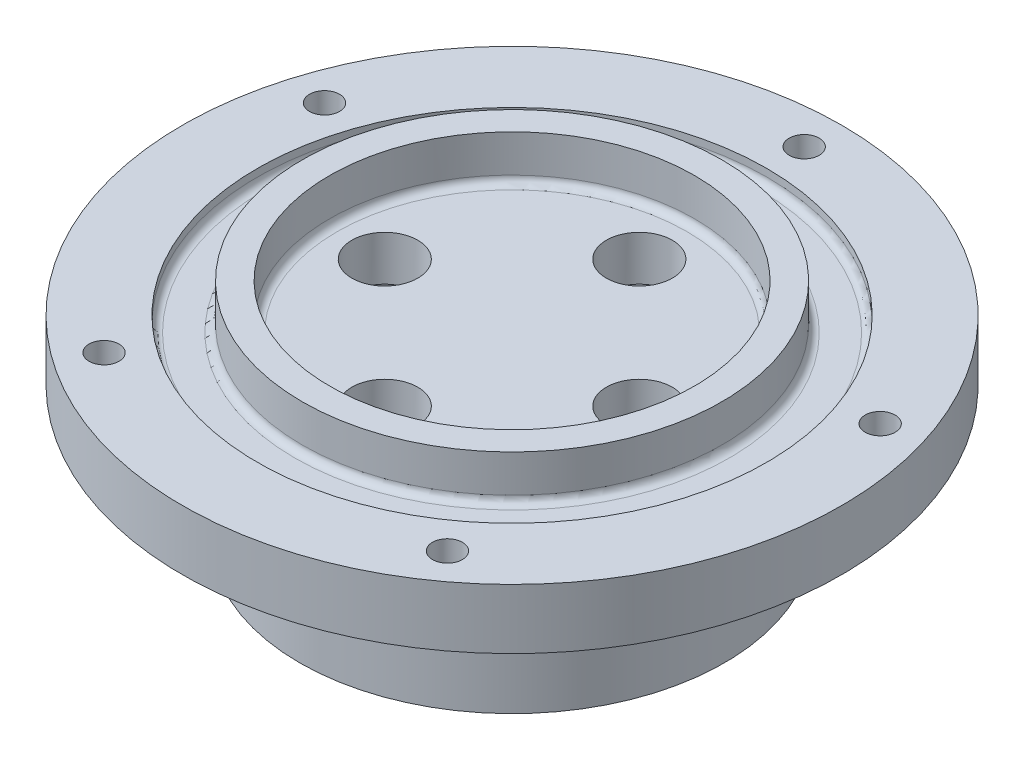
from build123d import *

# Parameters (mm, degrees)
SKETCH2_R          = 3.4925
CUT_EXTRUDE1_DEPTH = 53.937829102
SKETCH3_R          = 1.5875
CUT_EXTRUDE2_DEPTH = 54.529596078
CIRPATTERN1_COUNT  = 5
FILLET1_R          = 0.79375


with BuildPart() as part:
    # Sketch1 → Revolve1 (revolve)
    with BuildSketch(Plane.XY):
        Polygon((19.33575, -14.2875), (19.33575, 0), (0, 0), (0, 4.7625), (19.33575, 4.7625), (19.33575, 9.525), (22.225, 9.525), (22.225, 4.7625), (26.9875, 4.7625), (26.9875, 6.35), (34.925, 6.35), (34.925, 0), (22.51075, 0), (22.51075, -14.2875), align=None)
    revolve(axis=Axis((0, 0, 0), (0, 1, 0)))

    # Sketch2 → Cut-Extrude1 (cut, through all)
    with BuildSketch(Plane(origin=(0, 4.7625, 0), x_dir=(1, 0, 0), z_dir=(0, 1, 0))):
        with Locations((-13.4874, 0)):
            Circle(SKETCH2_R)
        with Locations((0, 13.4874)):
            Circle(SKETCH2_R)
        with Locations((13.4874, 0)):
            Circle(SKETCH2_R)
        with Locations((0, -13.4874)):
            Circle(SKETCH2_R)
    extrude(amount=-CUT_EXTRUDE1_DEPTH, mode=Mode.SUBTRACT)

    # Sketch3 → Cut-Extrude2 (cut, through all)
    with BuildSketch(Plane(origin=(0, 6.35, 0), x_dir=(1, 0, 0), z_dir=(0, 1, 0))):
        with Locations((0, 30.95625)):
            Circle(SKETCH3_R)
    cut_extrude2 = extrude(amount=-CUT_EXTRUDE2_DEPTH, mode=Mode.SUBTRACT)

    # CirPattern1: Cut-Extrude2 ×5 about axis
    cirpattern1_axis = Axis((0, 14.76375, 0), (0, -1, 0))
    for i in range(1, CIRPATTERN1_COUNT):
        add(cut_extrude2.rotate(cirpattern1_axis, i * 360 / CIRPATTERN1_COUNT), mode=Mode.SUBTRACT)

    # Fillet1
    fillet1_edges = [part.edges().sort_by_distance(p)[0] for p in [
        (-22.225, 4.7625, 0),
        (-26.9875, 4.7625, 0),
        (-19.33575, 4.7625, 0),
        (-19.33575, 0, 0),
    ]]
    fillet(fillet1_edges, radius=FILLET1_R)


solid = part.part
